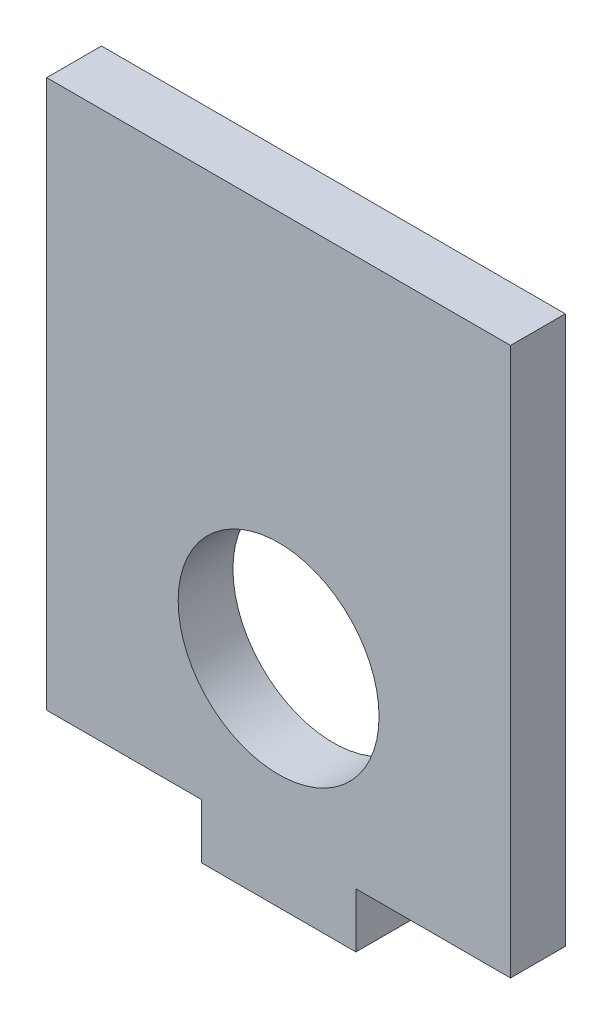
from build123d import *

# Parameters (mm, degrees)
SKETCH1_R           = 11
BOSS_EXTRUDE1_DEPTH = 6


with BuildPart() as part:
    # Sketch1 → Boss-Extrude1 (new body)
    with BuildSketch(Plane.XY):
        Polygon((-350.716937196, 225.798518154), (-350.716937196, 285.798518154), (-299.916937196, 285.798518154), (-299.916937196, 225.798518154), (-316.850270529, 225.798518154), (-316.850270529, 219.798518154), (-333.783603862, 219.798518154), (-333.783603862, 225.798518154), align=None)
        with Locations((-325.316937196, 243.398518154)):
            Circle(SKETCH1_R, mode=Mode.SUBTRACT)
    extrude(amount=BOSS_EXTRUDE1_DEPTH)


solid = part.part
